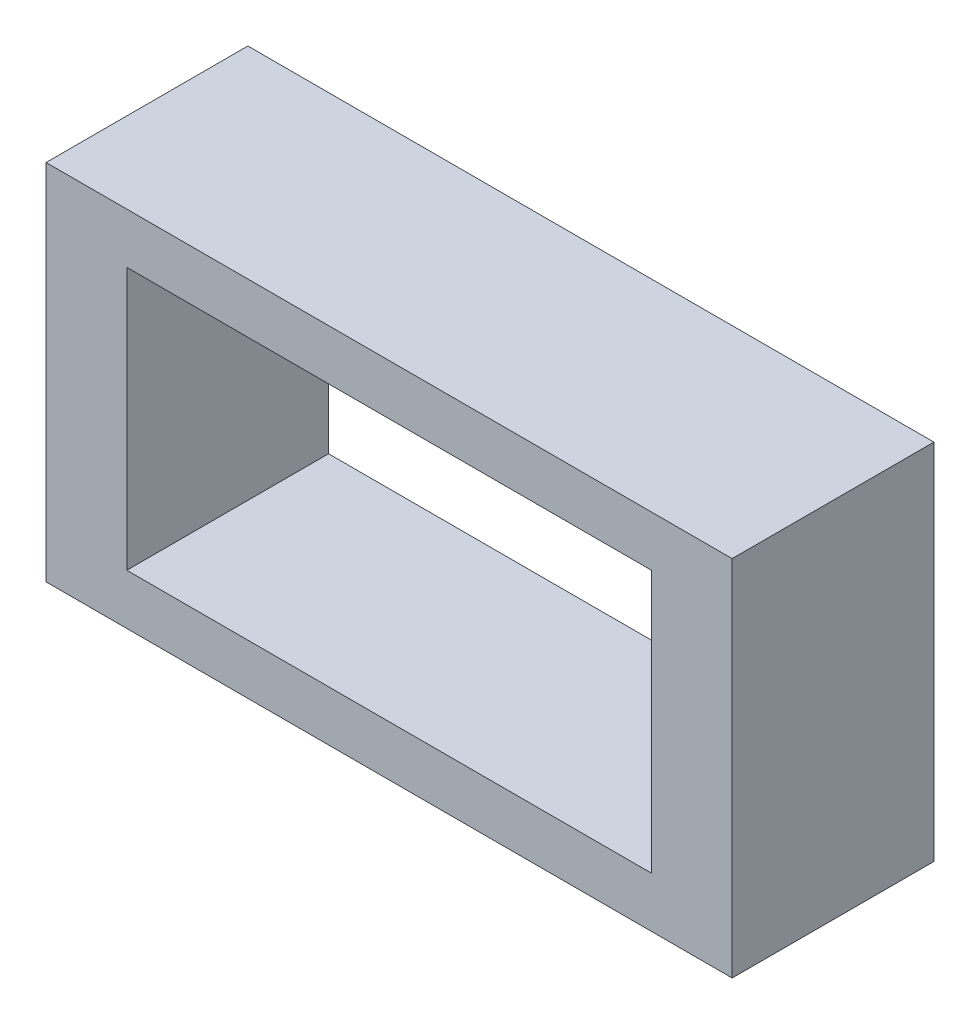
from build123d import *

# Parameters (mm, degrees)
ESQUISSE1_W             = 17
ESQUISSE1_H             = 9
BOSS_EXTRU_1_DEPTH      = 5
ESQUISSE2_W             = 13
ESQUISSE2_H             = 6.5
ENL_V_MAT_EXTRU_1_DEPTH = 5


with BuildPart() as part:
    # Esquisse1 → Boss.-Extru.1 (new body)
    with BuildSketch(Plane.XY):
        Rectangle(ESQUISSE1_W, ESQUISSE1_H)
    extrude(amount=BOSS_EXTRU_1_DEPTH)

    # Esquisse2 → Enlèv. mat.-Extru.1 (cut)
    with BuildSketch(Plane.XY.offset(5)):
        Rectangle(ESQUISSE2_W, ESQUISSE2_H)
    extrude(amount=-ENL_V_MAT_EXTRU_1_DEPTH, mode=Mode.SUBTRACT)


solid = part.part
